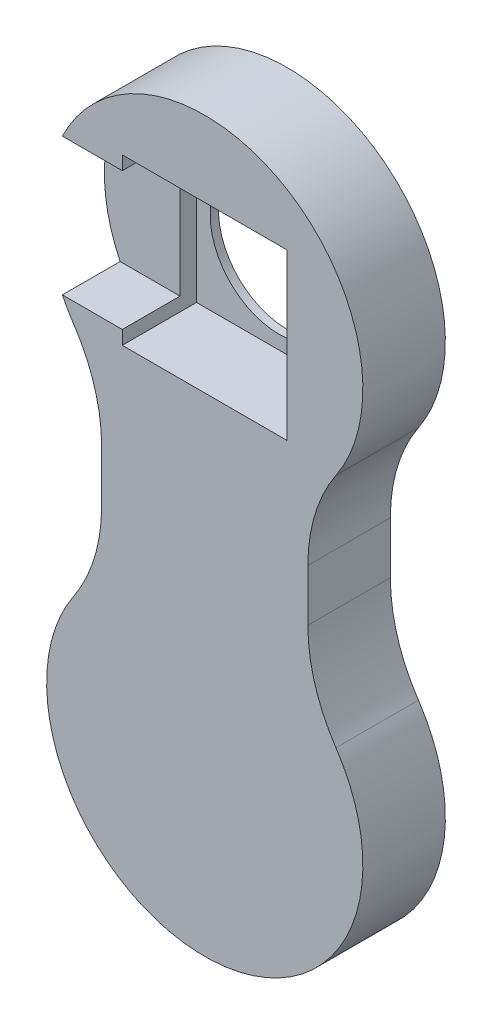
from build123d import *

# Parameters (mm, degrees)
BOSS_EXTRUDE1_DEPTH = 30
CUT_EXTRUDE1_DEPTH  = 35
FILLET1_R           = 60
SKETCH6_R           = 25
CUT_EXTRUDE2_DEPTH  = 31
CUT_EXTRUDE3_START  = -27
SKETCH7_W           = 60
SKETCH7_H           = 60
CUT_EXTRUDE3_DEPTH  = 27
SKETCH8_W           = 27.5
SKETCH8_H           = 50
CUT_EXTRUDE4_DEPTH  = 21


with BuildPart() as part:
    # Sketch3 → Boss-Extrude1 (new body)
    with BuildSketch(Plane.XY):
        with BuildLine():
            Line((-57.5, 0), (-57.5, 150))
            ThreePointArc((-57.5, 150), (0, 207.5), (57.5, 150))
            Line((57.5, 150), (57.5, 0))
            ThreePointArc((57.5, 0), (0, -57.5), (-57.5, 0))
        make_face()
    extrude(amount=BOSS_EXTRUDE1_DEPTH)

    # Sketch4 → Cut-Extrude1 (cut)
    with BuildSketch(Plane(origin=(0, 0, 0), x_dir=(-1, 0, 0), z_dir=(0, 0, -1))):
        with BuildLine():
            ThreePointArc((-57.5, 150), (-52.261362401, 126.020842383), (-37.5, 106.411010565))
            Line((-37.5, 106.411010565), (-37.5, 43.588989435))
            ThreePointArc((-37.5, 43.588989435), (-52.261362401, 23.979157617), (-57.5, 0))
            Line((-57.5, 0), (-57.5, 150))
        make_face()
        with BuildLine():
            ThreePointArc((57.5, 0), (52.261362401, 23.979157617), (37.5, 43.588989435))
            Line((37.5, 43.588989435), (37.5, 106.411010565))
            ThreePointArc((37.5, 106.411010565), (52.261362401, 126.020842383), (57.5, 150))
            Line((57.5, 150), (57.5, 0))
        make_face()
    extrude(amount=-CUT_EXTRUDE1_DEPTH, mode=Mode.SUBTRACT)

    # Fillet1
    fillet1_edges = [part.edges().sort_by_distance(p)[0] for p in [
        (37.5, 106.411010565, 15),
        (37.5, 43.588989435, 15),
        (-37.5, 43.588989435, 15),
        (-37.5, 106.411010565, 15),
    ]]
    fillet(fillet1_edges, radius=FILLET1_R)

    # Sketch6 → Cut-Extrude2 (cut, through all)
    with BuildSketch(Plane.XY.offset(30)):
        with Locations((0, 150)):
            Circle(SKETCH6_R)
    extrude(amount=-CUT_EXTRUDE2_DEPTH, mode=Mode.SUBTRACT)

    # Sketch7 → Cut-Extrude3 (cut)
    with BuildSketch(Plane.XY.offset(30).offset(CUT_EXTRUDE3_START)):
        with Locations((0, 150)):
            Rectangle(SKETCH7_W, SKETCH7_H)
    extrude(amount=CUT_EXTRUDE3_DEPTH, mode=Mode.SUBTRACT)

    # Sketch8 → Cut-Extrude4 (cut)
    with BuildSketch(Plane.XY.offset(30)):
        with Locations((-43.75, 150)):
            Rectangle(SKETCH8_W, SKETCH8_H)
    extrude(amount=-CUT_EXTRUDE4_DEPTH, mode=Mode.SUBTRACT)


solid = part.part
